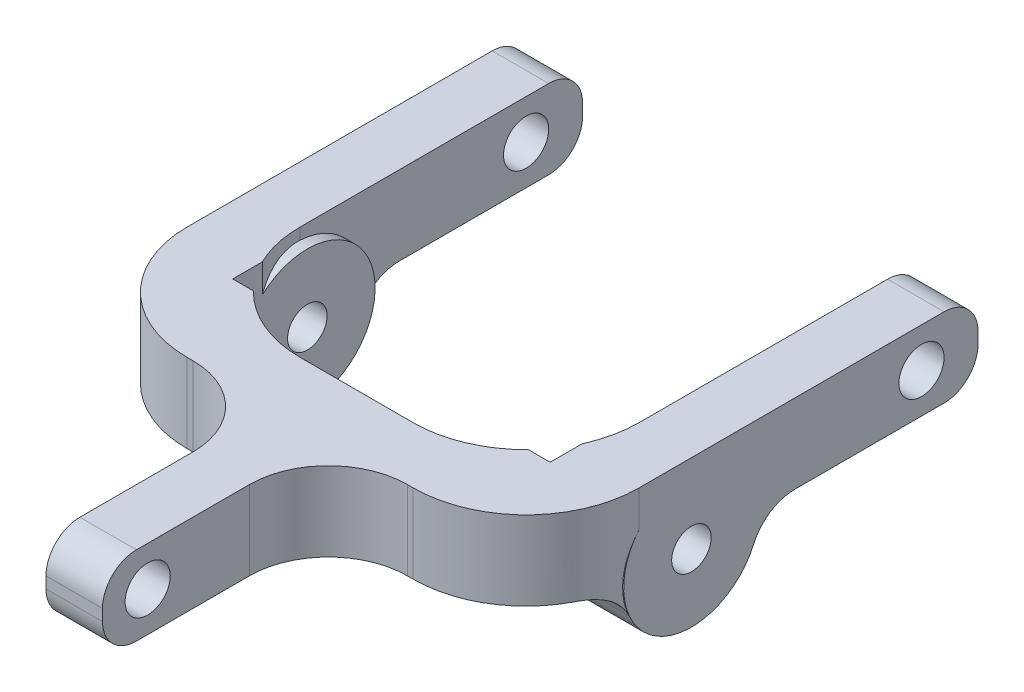
from build123d import *

# Parameters (mm, degrees)
SKETCH1_W               = 40
SKETCH1_H               = 7
BOSS_EXTRUDE1_DEPTH     = 40
CUT_EXTRUDE1_DEPTH      = 8
FILLET1_R               = 10
SKETCH5_W               = 5
SKETCH5_H               = 7
BOSS_EXTRUDE2_DEPTH     = 20
FILLET2_R               = 7
FILLET3_R               = 3
SKETCH6_R               = 2
CUT_EXTRUDE2_DEPTH      = 41
SKETCH7_R               = 2
CUT_EXTRUDE3_DEPTH      = 23.5
SKETCH8_R               = 6
BOSS_EXTRUDE3_DEPTH     = 40
SKETCH9_W               = 28.10166571
SKETCH9_H               = 14.198736358
CUT_EXTRUDE4_DEPTH      = 4.5000001
CUT_EXTRUDE4_DEPTH_BACK = 10.5000001
SKETCH10_R              = 1.75
CUT_EXTRUDE5_DEPTH      = 41.0000001
FILLET4_R               = 4


with BuildPart() as part:
    # Sketch1 → Boss-Extrude1 (new body)
    with BuildSketch(Plane(origin=(0, 0, 0), x_dir=(0, 0, -1), z_dir=(1, 0, 0))):
        Rectangle(SKETCH1_W, SKETCH1_H)
    extrude(amount=BOSS_EXTRUDE1_DEPTH)

    # Sketch2 → Cut-Extrude1 (cut, through all)
    with BuildSketch(Plane(origin=(0, 3.5, 0), x_dir=(1, 0, 0), z_dir=(0, 1, 0))):
        with BuildLine():
            Line((5, 20), (35, 20))
            Line((35, 20), (35, -5))
            ThreePointArc((35, -5), (32.071067812, -12.071067812), (25, -15))
            Line((25, -15), (15, -15))
            ThreePointArc((15, -15), (7.928932188, -12.071067812), (5, -5))
            Line((5, -5), (5, 20))
        make_face()
    extrude(amount=-CUT_EXTRUDE1_DEPTH, mode=Mode.SUBTRACT)

    # Fillet1
    fillet1_edges = [part.edges().sort_by_distance(p)[0] for p in [
        (40, 0, 20),
        (0, 0, 20),
    ]]
    fillet(fillet1_edges, radius=FILLET1_R)

    # Sketch5 → Boss-Extrude2 (add)
    with BuildSketch(Plane.XY.offset(20)):
        with Locations((20, 0)):
            Rectangle(SKETCH5_W, SKETCH5_H)
    extrude(amount=BOSS_EXTRUDE2_DEPTH)

    # Fillet2
    fillet2_edges = [part.edges().sort_by_distance(p)[0] for p in [
        (17.5, 0, 20),
        (22.5, 0, 20),
    ]]
    fillet(fillet2_edges, radius=FILLET2_R)

    # Fillet3
    fillet3_edges = [part.edges().sort_by_distance(p)[0] for p in [
        (2.5, -3.5, -20),
        (2.5, 3.5, -20),
        (20, -3.5, 40),
        (20, 3.5, 40),
        (37.5, -3.5, -20),
        (37.5, 3.5, -20),
    ]]
    fillet(fillet3_edges, radius=FILLET3_R)

    # Sketch6 → Cut-Extrude2 (cut, through all)
    with BuildSketch(Plane(origin=(40, 0, 0), x_dir=(0, 0, -1), z_dir=(1, 0, 0))):
        with Locations((15, 0)):
            Circle(SKETCH6_R)
    extrude(amount=-CUT_EXTRUDE2_DEPTH, mode=Mode.SUBTRACT)

    # Sketch7 → Cut-Extrude3 (cut, through all)
    with BuildSketch(Plane(origin=(22.5, 0, 0), x_dir=(0, 0, -1), z_dir=(1, 0, 0))):
        with Locations((-36, 0)):
            Circle(SKETCH7_R)
    extrude(amount=-CUT_EXTRUDE3_DEPTH, mode=Mode.SUBTRACT)

    # Sketch8 → Boss-Extrude3 (add)
    with BuildSketch(Plane(origin=(40, 0, 0), x_dir=(0, 0, -1), z_dir=(1, 0, 0))):
        with Locations((-5.366027913, -3.5)):
            Circle(SKETCH8_R)
    extrude(amount=-BOSS_EXTRUDE3_DEPTH)

    # Sketch9 → Cut-Extrude4 (cut, two sides)
    with BuildSketch(Plane(origin=(0, 0, 0), x_dir=(1, 0, 0), z_dir=(0, 1, 0))) as cut_extrude4_sk:
        with Locations((20.049301168, -4.872678537)):
            Rectangle(SKETCH9_W, SKETCH9_H)
    extrude(amount=CUT_EXTRUDE4_DEPTH, mode=Mode.SUBTRACT)
    extrude(cut_extrude4_sk.sketch, amount=-CUT_EXTRUDE4_DEPTH_BACK, mode=Mode.SUBTRACT)

    # Sketch10 → Cut-Extrude5 (cut, through all)
    with BuildSketch(Plane(origin=(40, 0, 0), x_dir=(0, 0, -1), z_dir=(1, 0, 0))):
        with Locations((-5.366027913, -3.5)):
            Circle(SKETCH10_R)
    extrude(amount=-CUT_EXTRUDE5_DEPTH, mode=Mode.SUBTRACT)

    # Fillet4
    fillet4_edges = [part.edges().sort_by_distance(p)[0] for p in [
        (37.5, -3.5, -0.633972087),
        (2.5, -3.5, -0.633972087),
        (3.046104647, -3.5, 11.366027913),
        (37.00319652, -3.5, 11.366027913),
    ]]
    fillet(fillet4_edges, radius=FILLET4_R)


solid = part.part
